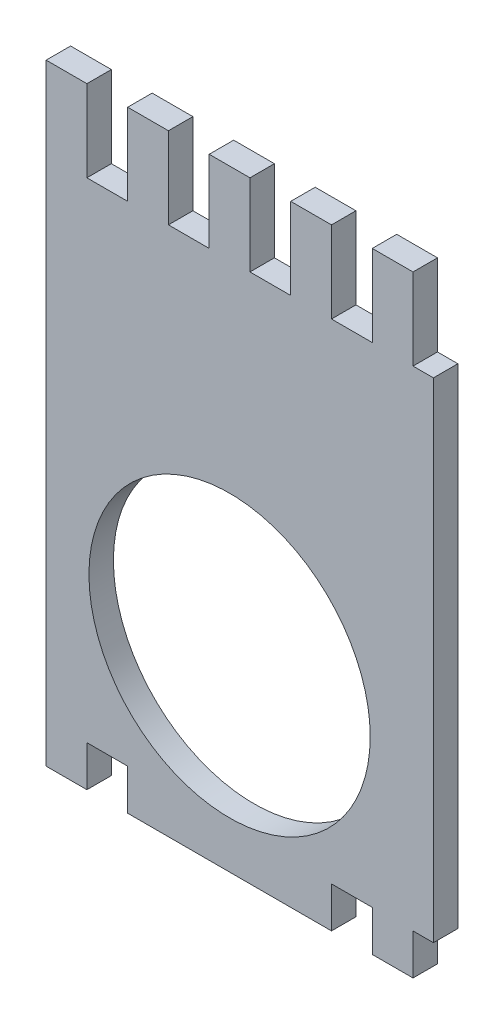
from build123d import *

# Parameters (mm, degrees)
ESQUISSE3_W                = 50
ESQUISSE3_H                = 60
BOSS_EXTRU_12_DEPTH        = 3
ESQUISSE4_R                = 17.25
ENL_V_MAT_EXTRU_1_DEPTH    = 5
ESQUISSE5_W                = 5
ESQUISSE5_H                = 10
ESQUISSE5_H_2              = 5
BOSS_EXTRU_13_DEPTH        = 3
R_P_TITION_LIN_AIRE1_COUNT = 5
R_P_TITION_LIN_AIRE1_PITCH = 10
ESQUISSE6_W                = 5
ESQUISSE6_H                = 5
BOSS_EXTRU_14_DEPTH        = 3
ESQUISSE7_W                = 2.5
ESQUISSE7_H                = 60
ENL_V_MAT_EXTRU_2_DEPTH    = 10


with BuildPart() as part:
    # Esquisse3 → Boss.-Extru.12 (new body)
    with BuildSketch(Plane.XY):
        with Locations((0, -10)):
            Rectangle(ESQUISSE3_W, ESQUISSE3_H)
    extrude(amount=BOSS_EXTRU_12_DEPTH)

    # Esquisse4 → Enlèv. mat.-Extru.1 (cut)
    with BuildSketch(Plane.XY.offset(3)):
        with Locations((0, -22)):
            Circle(ESQUISSE4_R)
    extrude(amount=-ENL_V_MAT_EXTRU_1_DEPTH, mode=Mode.SUBTRACT)

    # Esquisse5 → Boss.-Extru.13 (add)
    with BuildSketch(Plane.XY.offset(3)):
        with Locations((-20, 25)):
            Rectangle(ESQUISSE5_W, ESQUISSE5_H)
        with Locations((-20, -42.5)):
            Rectangle(ESQUISSE5_W, ESQUISSE5_H_2)
    boss_extru_13 = extrude(amount=-BOSS_EXTRU_13_DEPTH)

    # Répétition linéaire1: Boss.-Extru.13 ×5
    with Locations(*[(i * R_P_TITION_LIN_AIRE1_PITCH, 0, 0) for i in range(1, R_P_TITION_LIN_AIRE1_COUNT)]):
        add(boss_extru_13)

    # Esquisse6 → Boss.-Extru.14 (add)
    with BuildSketch(Plane.XY.offset(3)):
        with Locations((-5, -42.5)):
            Rectangle(ESQUISSE6_W, ESQUISSE6_H)
        with Locations((5, -42.5)):
            Rectangle(ESQUISSE6_W, ESQUISSE6_H)
    extrude(amount=-BOSS_EXTRU_14_DEPTH)

    # Esquisse7 → Enlèv. mat.-Extru.2 (cut)
    with BuildSketch(Plane.XY.offset(3)):
        with Locations((-23.75, -10)):
            Rectangle(ESQUISSE7_W, ESQUISSE7_H)
    extrude(amount=-ENL_V_MAT_EXTRU_2_DEPTH, mode=Mode.SUBTRACT)


solid = part.part
